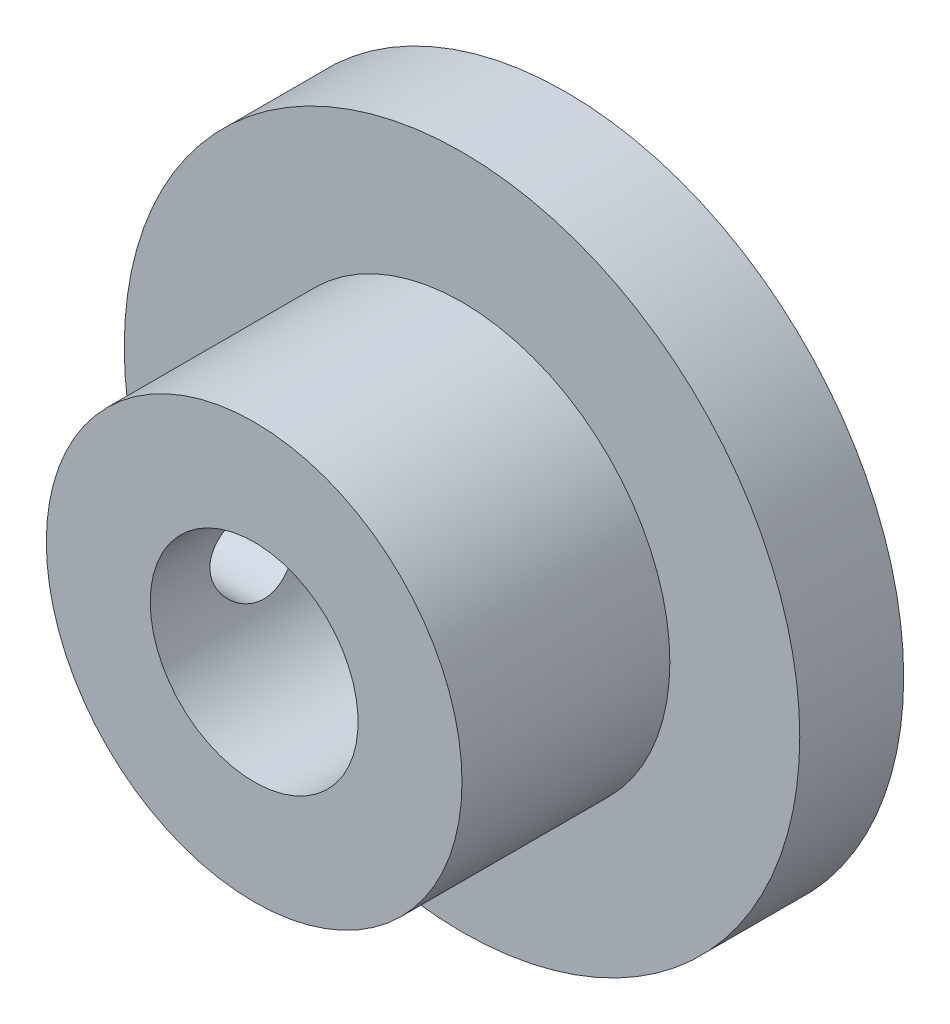
from build123d import *

# Parameters (mm, degrees)
SKETCH1_R                  = 10.31875
BOSS_EXTRUDE1_DEPTH        = 3.175
SKETCH2_R                  = 6.35
BOSS_EXTRUDE2_DEPTH        = 6.35
SKETCH3_R                  = 3.175
CUT_EXTRUDE1_DEPTH         = 18.426383105
F_6_32_TAPPED_HOLE1_REACH  = 23.796
F_6_32_TAPPED_HOLE1_BORE_R = 1.35255


with BuildPart() as part:
    # Sketch1 → Boss-Extrude1 (new body)
    with BuildSketch(Plane.XY):
        Circle(SKETCH1_R)
    extrude(amount=BOSS_EXTRUDE1_DEPTH)

    # Sketch2 → Boss-Extrude2 (add)
    with BuildSketch(Plane.XY.offset(3.175)):
        Circle(SKETCH2_R)
    extrude(amount=BOSS_EXTRUDE2_DEPTH)

    # Sketch3 → Cut-Extrude1 (cut, through all)
    with BuildSketch(Plane(origin=(0, 0, 0), x_dir=(-1, 0, 0), z_dir=(0, 0, -1))):
        Circle(SKETCH3_R)
    extrude(amount=-CUT_EXTRUDE1_DEPTH, mode=Mode.SUBTRACT)

    # #6-32 Tapped Hole1 bore → #6-32 Tapped Hole1 (cut, up to next)
    with BuildSketch(Plane.ZY.offset(6.35), mode=Mode.PRIVATE) as f_6_32_tapped_hole1_sk1:
        with Locations((6.35, 0)):
            Circle(F_6_32_TAPPED_HOLE1_BORE_R)
    f_6_32_tapped_hole1_tool1 = extrude(f_6_32_tapped_hole1_sk1.sketch, amount=-F_6_32_TAPPED_HOLE1_REACH, mode=Mode.PRIVATE) & part.part
    add(f_6_32_tapped_hole1_tool1.solids().sort_by_distance((-6.35, 0, 6.35))[0], mode=Mode.SUBTRACT)


solid = part.part
